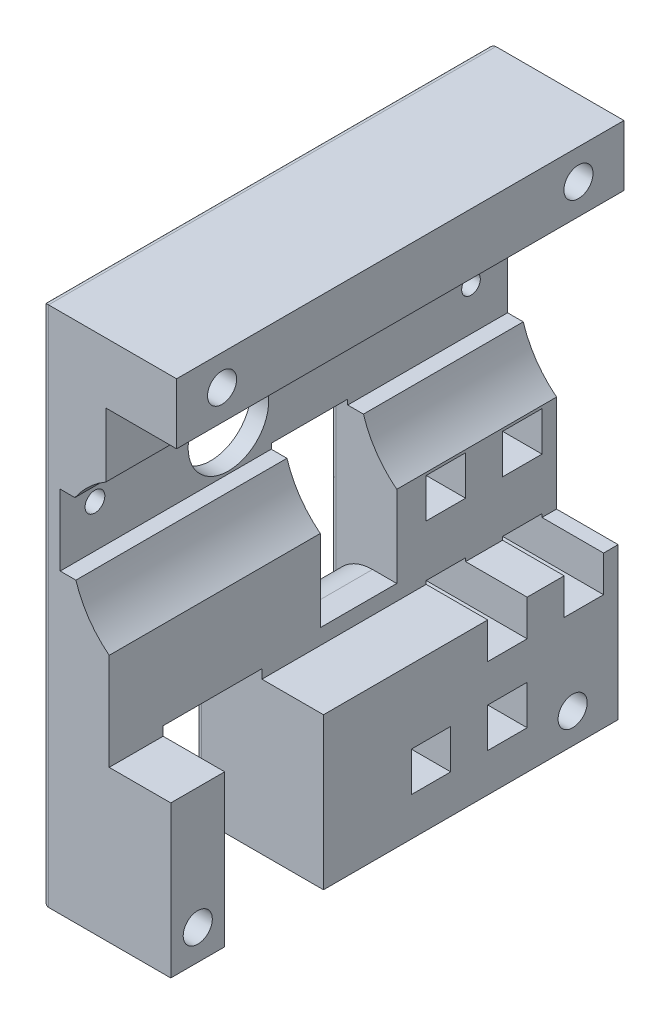
from build123d import *

# Parameters (mm, degrees)
PROFILEEXTRUDE_DEPTH    = 73.76
HOSEWINDOW_W            = 16.29
HOSEWINDOW_H            = 26.5
HOSEWINDOWCUT_DEPTH     = 23.11
CAGESCREWS_R            = 2.4
CAGESCREWSCUT_DEPTH     = 23.11
AXLEHOLECUT_DEPTH       = 23.11
SETSCREWHOLES_R         = 1.539432213
SETSCREWHOLES_R_2       = 1.628953018
SETSCREWHOLESCUT_DEPTH  = 23.11
VELOCITYWINDOW_W        = 12.61
VELOCITYWINDOW_H        = 22.29
VELOCITYWINDOWCUT_DEPTH = 23.11
FILLET3_R               = 7
TRIGGERRACKSLOTCUT_W    = 6.5
TRIGGERRACKSLOTCUT_H    = 6.5
RACKSLOTCUT_DEPTH       = 23.11
FILLET4_R               = 1


with BuildPart() as part:
    # Profile → ProfileExtrude (new body)
    with BuildSketch(Plane.XY):
        with BuildLine():
            Line((9.301269376, -54.194713793), (9.301269376, -29.194713793))
            Line((9.301269376, -29.194713793), (-0.848730624, -29.194713793))
            Line((-0.848730624, -29.194713793), (-0.848730624, -13.196583793))
            ThreePointArc((-0.848730624, -13.196583793), (-4.204324299, -9.619560571), (-6.340730624, -5.204713793))
            Line((-6.340730624, -5.204713793), (-8.928730624, -5.204713793))
            Line((-8.928730624, -5.204713793), (-8.928730624, 6.495286207))
            Line((-8.928730624, 6.495286207), (-6.509650624, 6.495286207))
            ThreePointArc((-6.509650624, 6.495286207), (-4.210311879, 9.168674207), (-1.388730624, 11.283536207))
            Line((-1.388730624, 11.283536207), (-1.388730624, 21.845286207))
            Line((-1.388730624, 21.845286207), (10.261269376, 21.845286207))
            Line((10.261269376, 21.845286207), (10.261269376, 31.845286207))
            Line((10.261269376, 31.845286207), (-11.848730624, 31.845286207))
            Line((-11.848730624, 31.845286207), (-11.848730624, -54.194713793))
            Line((-11.848730624, -54.194713793), (9.301269376, -54.194713793))
        make_face()
    extrude(amount=PROFILEEXTRUDE_DEPTH)

    # HoseWindow → HoseWindowCut (cut, through all)
    with BuildSketch(Plane.ZY.offset(11.848730624)):
        with Locations((56.725, -40.944713793)):
            Rectangle(HOSEWINDOW_W, HOSEWINDOW_H)
    extrude(amount=-HOSEWINDOWCUT_DEPTH, mode=Mode.SUBTRACT)

    # CageScrews → CageScrewsCut (cut, through all)
    with BuildSketch(Plane.ZY.offset(11.848730624)):
        with Locations((7.5, 26.845286207)):
            Circle(CAGESCREWS_R)
        with Locations((66.26, 26.845286207)):
            Circle(CAGESCREWS_R)
        with Locations((7.5, -49.194713793)):
            Circle(CAGESCREWS_R)
        with Locations((69.31, -49.194713793)):
            Circle(CAGESCREWS_R)
    extrude(amount=-CAGESCREWSCUT_DEPTH, mode=Mode.SUBTRACT)

    # AxleHole → AxleHoleCut (cut, through all)
    with BuildSketch(Plane.ZY.offset(11.848730624)):
        with BuildLine():
            Line((47.361, 8.359497151), (47.361, 6.740497151))
            Line((47.361, 6.740497151), (44.699, 6.740497151))
            Line((44.699, 6.740497151), (44.699, 8.359497151))
            ThreePointArc((44.699, 8.359497151), (46.03, -4.783713793), (47.361, 8.359497151))
        make_face()
    extrude(amount=-AXLEHOLECUT_DEPTH, mode=Mode.SUBTRACT)

    # SetScrewHoles → SetScrewHolesCut (cut, through all)
    with BuildSketch(Plane.ZY.offset(11.848730624)):
        with Locations((6.03, 1.855286207)):
            Circle(SETSCREWHOLES_R)
        with Locations((68.03, 1.855286207)):
            Circle(SETSCREWHOLES_R_2)
    extrude(amount=-SETSCREWHOLESCUT_DEPTH, mode=Mode.SUBTRACT)

    # VelocityWindow → VelocityWindowCut (cut, through all)
    with BuildSketch(Plane.ZY.offset(11.848730624)):
        with Locations((32.655, -15.499713793)):
            Rectangle(VELOCITYWINDOW_W, VELOCITYWINDOW_H)
    extrude(amount=-VELOCITYWINDOWCUT_DEPTH, mode=Mode.SUBTRACT)

    # Fillet3
    fillet3_edges = [part.edges().sort_by_distance(p)[0] for p in [
        (-11.848730624, -26.644713793, 32.655),
    ]]
    fillet(fillet3_edges, radius=FILLET3_R)

    # TriggerRackSlotCut → RackSlotCut (cut, through all)
    with BuildSketch(Plane.ZY.offset(11.848730624)):
        with Locations((18.25, -44.594713793)):
            Rectangle(TRIGGERRACKSLOTCUT_W, TRIGGERRACKSLOTCUT_H)
        with Locations((30.85, -44.594713793)):
            Rectangle(TRIGGERRACKSLOTCUT_W, TRIGGERRACKSLOTCUT_H)
        with Locations((5.65, -31.894713793)):
            Rectangle(TRIGGERRACKSLOTCUT_W, TRIGGERRACKSLOTCUT_H)
        with Locations((18.25, -31.894713793)):
            Rectangle(TRIGGERRACKSLOTCUT_W, TRIGGERRACKSLOTCUT_H)
        with Locations((5.65, -16.894713793)):
            Rectangle(TRIGGERRACKSLOTCUT_W, TRIGGERRACKSLOTCUT_H)
        with Locations((18.25, -16.894713793)):
            Rectangle(TRIGGERRACKSLOTCUT_W, TRIGGERRACKSLOTCUT_H)
    extrude(amount=-RACKSLOTCUT_DEPTH, mode=Mode.SUBTRACT)

    # Fillet4
    fillet4_edges = [part.edges().sort_by_distance(p)[0] for p in [
        (-11.848730624, -11.174713793, 73.76),
        (-11.848730624, -18.999713793, 26.35),
        (-11.848730624, -18.999713793, 38.96),
        (-11.848730624, -4.354713793, 32.655),
        (-11.848730624, -44.594713793, 15),
        (-11.848730624, -47.844713793, 18.25),
        (-11.848730624, -44.594713793, 21.5),
        (-11.848730624, -41.344713793, 18.25),
        (-11.848730624, -11.174713793, 0),
        (-11.848730624, -44.594713793, 27.6),
        (-11.848730624, -47.844713793, 30.85),
        (-11.848730624, -44.594713793, 34.1),
        (-11.848730624, -41.344713793, 30.85),
        (-11.848730624, -31.894713793, 2.4),
        (-11.848730624, -35.144713793, 5.65),
        (-11.848730624, -31.894713793, 8.9),
        (-11.848730624, -28.644713793, 5.65),
        (-11.848730624, -31.894713793, 15),
        (-11.848730624, -35.144713793, 18.25),
        (-11.848730624, -31.894713793, 21.5),
        (-11.848730624, -28.644713793, 18.25),
        (-11.848730624, -54.194713793, 69.315),
        (-11.848730624, 31.845286207, 36.88),
        (-11.848730624, -16.894713793, 2.4),
        (-11.848730624, -20.144713793, 5.65),
        (-11.848730624, -16.894713793, 8.9),
        (-11.848730624, -13.644713793, 5.65),
        (-11.848730624, -16.894713793, 15),
        (-11.848730624, -20.144713793, 18.25),
        (-11.848730624, -16.894713793, 21.5),
        (-11.848730624, -13.644713793, 18.25),
        (-11.848730624, -54.194713793, 24.29),
        (-11.848730624, -40.944713793, 64.87),
        (-11.848730624, -27.694713793, 56.725),
        (-11.848730624, -40.944713793, 48.58),
    ]]
    fillet(fillet4_edges, radius=FILLET4_R)


solid = part.part
